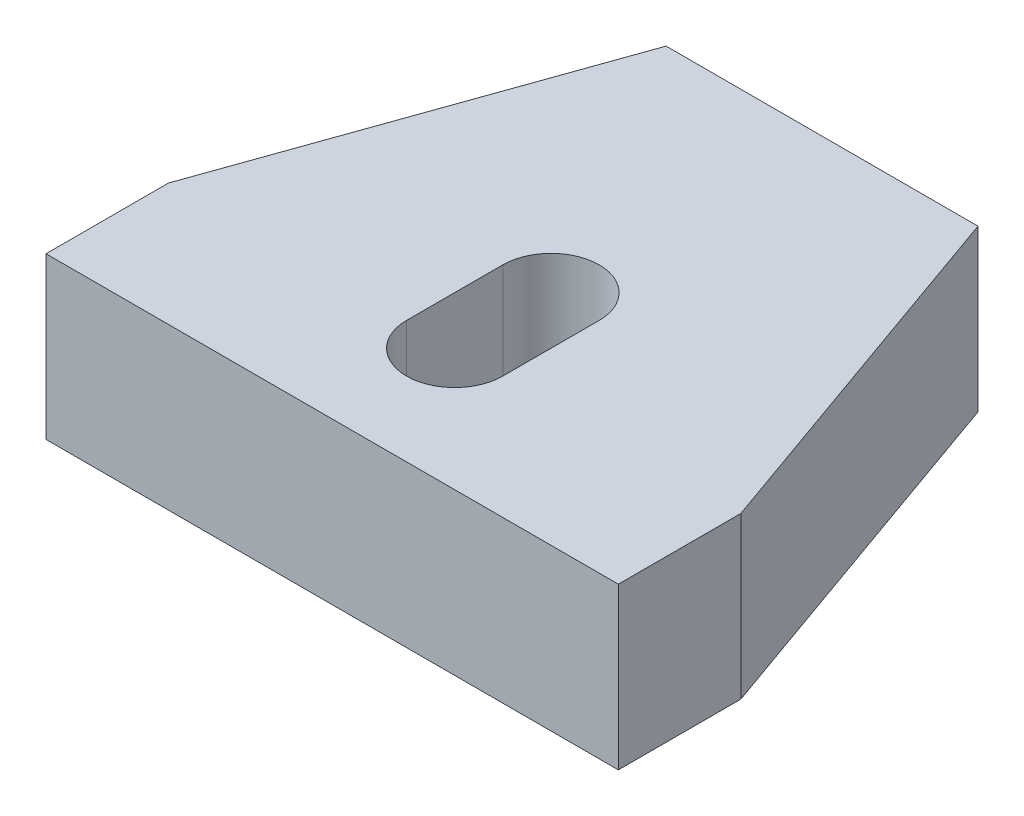
from build123d import *

# Parameters (mm, degrees)
BOSS_EXTRUDE1_DEPTH = 5.0038


with BuildPart() as part:
    # Sketch1 → Boss-Extrude1 (new body)
    with BuildSketch(Plane(origin=(0, 0, 0), x_dir=(1, 0, 0), z_dir=(0, 1, 0))):
        Polygon((-8.9027, 0), (8.9027, 0), (8.9027, 3.81), (4.8514, 15.24), (-4.8514, 15.24), (-8.9027, 3.81), align=None)
        with BuildLine():
            Line((-1.4986, 3.81), (-1.4986, 6.8072))
            ThreePointArc((-1.4986, 6.8072), (0, 8.3058), (1.4986, 6.8072))
            Line((1.4986, 6.8072), (1.4986, 3.81))
            ThreePointArc((1.4986, 3.81), (0, 2.3114), (-1.4986, 3.81))
        make_face(mode=Mode.SUBTRACT)
    extrude(amount=BOSS_EXTRUDE1_DEPTH)


solid = part.part
